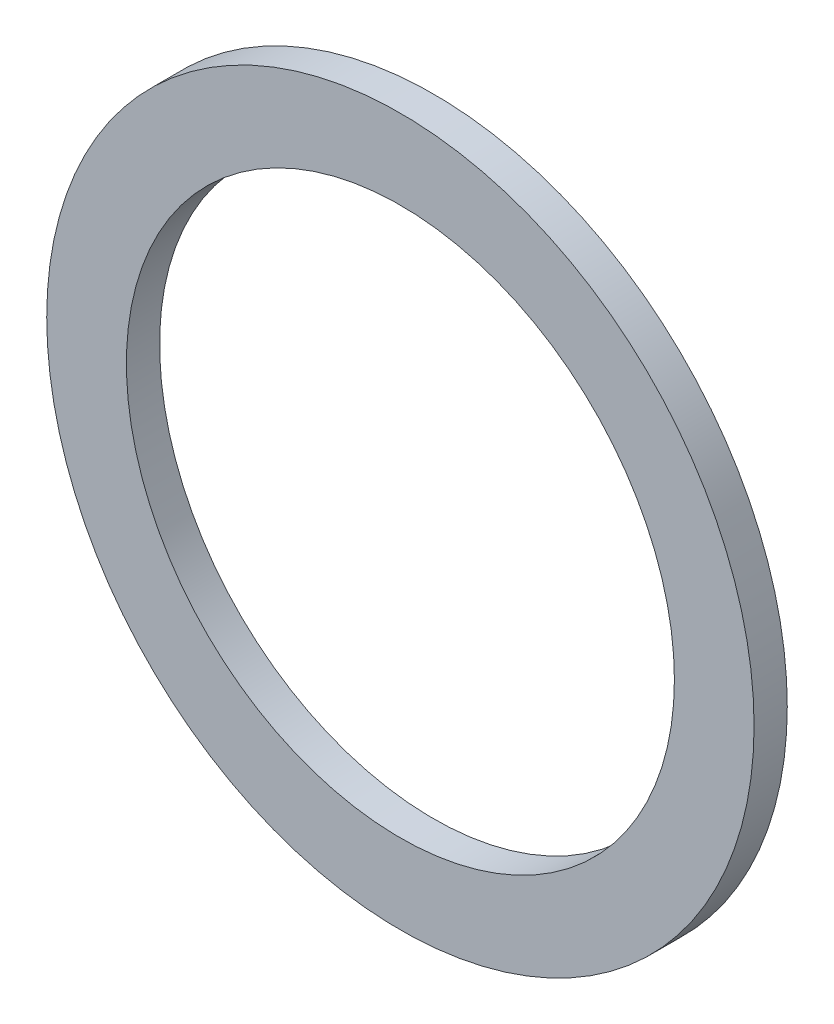
from build123d import *

# Parameters (mm, degrees)
SKETCH1_R           = 5.327
SKETCH1_R_2         = 4.127
BOSS_EXTRUDE1_DEPTH = 0.5


with BuildPart() as part:
    # Sketch1 → Boss-Extrude1 (new body)
    with BuildSketch(Plane.XY):
        Circle(SKETCH1_R)
        Circle(SKETCH1_R_2, mode=Mode.SUBTRACT)
    extrude(amount=BOSS_EXTRUDE1_DEPTH)


solid = part.part
